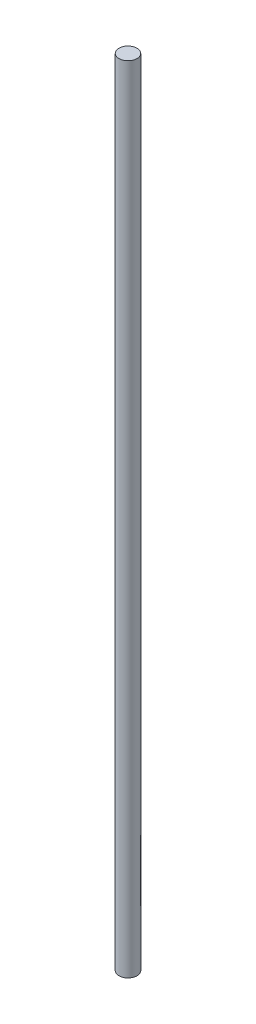
from build123d import *

# Parameters (mm, degrees)
SKETCH1_R           = 6.35
BOSS_EXTRUDE1_DEPTH = 558.8


with BuildPart() as part:
    # Sketch1 → Boss-Extrude1 (new body)
    with BuildSketch(Plane(origin=(0, 0, 0), x_dir=(1, 0, 0), z_dir=(0, 1, 0))):
        Circle(SKETCH1_R)
    extrude(amount=BOSS_EXTRUDE1_DEPTH)


solid = part.part
